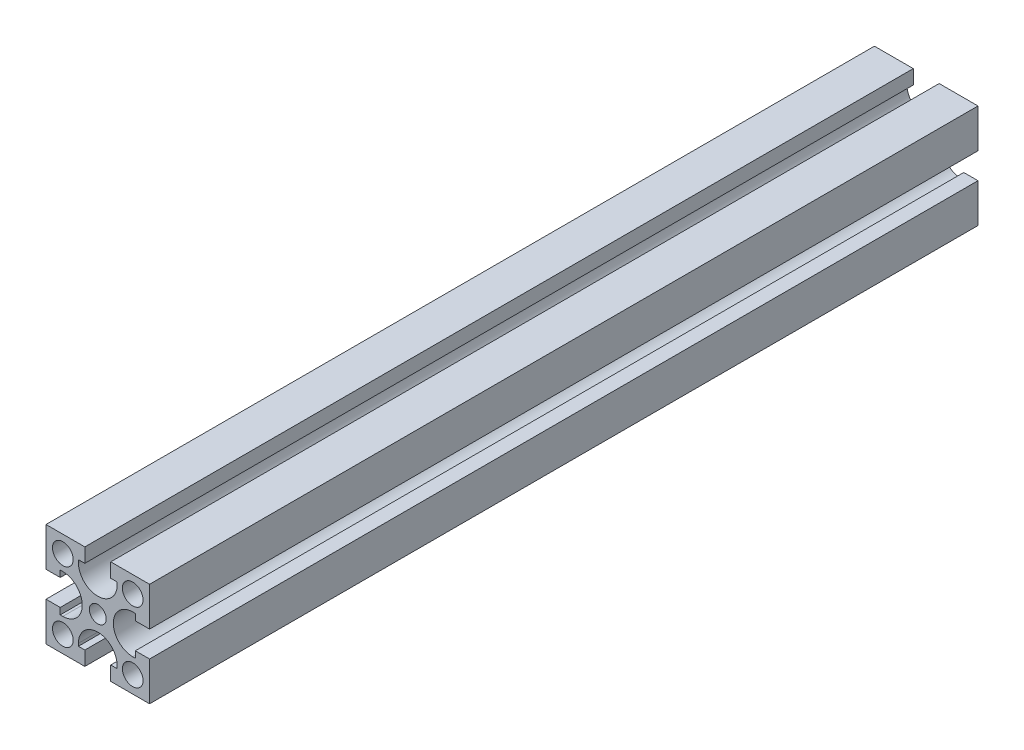
from build123d import *

# Parameters (mm, degrees)
SKETCH_1_W                  = 40
SKETCH_1_H                  = 40
EXTRUDE_1_DEPTH             = 320
SKETCH_2_R                  = 3.25
SKETCH_2_R_2                = 4
CUT_EXTRUDE_1_DEPTH         = 321
HOLE_WIZARD_3_5_3_5_1_D     = 3.5
HOLE_WIZARD_3_5_3_5_1_DEPTH = 7.5
HOLE_WIZARD_3_5_3_5_1_TIP   = 1.051506083


with BuildPart() as part:
    # 草圖1 → 伸長1 (new body)
    with BuildSketch(Plane.XY):
        Rectangle(SKETCH_1_W, SKETCH_1_H)
    extrude(amount=EXTRUDE_1_DEPTH)

    # 草圖2 → 除料-伸長1 (cut, through all)
    with BuildSketch(Plane(origin=(0, 0, 0), x_dir=(-1, 0, 0), z_dir=(0, 0, -1))):
        Circle(SKETCH_2_R)
        with Locations((-13.5, 13.5)):
            Circle(SKETCH_2_R_2)
        with Locations((13.5, 13.5)):
            Circle(SKETCH_2_R_2)
        with Locations((-13.5, -13.5)):
            Circle(SKETCH_2_R_2)
        with Locations((13.5, -13.5)):
            Circle(SKETCH_2_R_2)
        with BuildLine():
            Line((5, 14.5), (7.5, 14.5))
            Line((7.5, 14.5), (7.5, 13.5))
            ThreePointArc((7.5, 13.5), (0, 6), (-7.5, 13.5))
            Line((-7.5, 13.5), (-7.5, 14.5))
            Line((-7.5, 14.5), (-5, 14.5))
            Line((-5, 14.5), (-5, 20))
            Line((-5, 20), (5, 20))
            Line((5, 20), (5, 14.5))
        make_face()
        with BuildLine():
            Line((14.5, -5), (14.5, -7.5))
            Line((14.5, -7.5), (13.5, -7.5))
            ThreePointArc((13.5, -7.5), (6, 0), (13.5, 7.5))
            Line((13.5, 7.5), (14.5, 7.5))
            Line((14.5, 7.5), (14.5, 5))
            Line((14.5, 5), (20, 5))
            Line((20, 5), (20, -5))
            Line((20, -5), (14.5, -5))
        make_face()
        with BuildLine():
            Line((-5, -14.5), (-7.5, -14.5))
            Line((-7.5, -14.5), (-7.5, -13.5))
            ThreePointArc((-7.5, -13.5), (0, -6), (7.5, -13.5))
            Line((7.5, -13.5), (7.5, -14.5))
            Line((7.5, -14.5), (5, -14.5))
            Line((5, -14.5), (5, -20))
            Line((5, -20), (-5, -20))
            Line((-5, -20), (-5, -14.5))
        make_face()
        with BuildLine():
            Line((-14.5, 5), (-14.5, 7.5))
            Line((-14.5, 7.5), (-13.5, 7.5))
            ThreePointArc((-13.5, 7.5), (-6, 0), (-13.5, -7.5))
            Line((-13.5, -7.5), (-14.5, -7.5))
            Line((-14.5, -7.5), (-14.5, -5))
            Line((-14.5, -5), (-20, -5))
            Line((-20, -5), (-20, 5))
            Line((-20, 5), (-14.5, 5))
        make_face()
    extrude(amount=-CUT_EXTRUDE_1_DEPTH, mode=Mode.SUBTRACT)

    # Ø3.5 (3.5) 直徑孔1
    with Locations(Plane(origin=(0, -20, 0), x_dir=(-1, 0, 0), z_dir=(0, -1, 0))):
        with Locations((-16, -145), (-16, -175), (14, -145), (14, -175)):
            Hole(HOLE_WIZARD_3_5_3_5_1_D / 2, depth=HOLE_WIZARD_3_5_3_5_1_DEPTH)
            with Locations((0, 0, -(HOLE_WIZARD_3_5_3_5_1_DEPTH + HOLE_WIZARD_3_5_3_5_1_TIP / 2))):  # 118° drill point
                Cone(0, HOLE_WIZARD_3_5_3_5_1_D / 2, HOLE_WIZARD_3_5_3_5_1_TIP, mode=Mode.SUBTRACT)


solid = part.part
